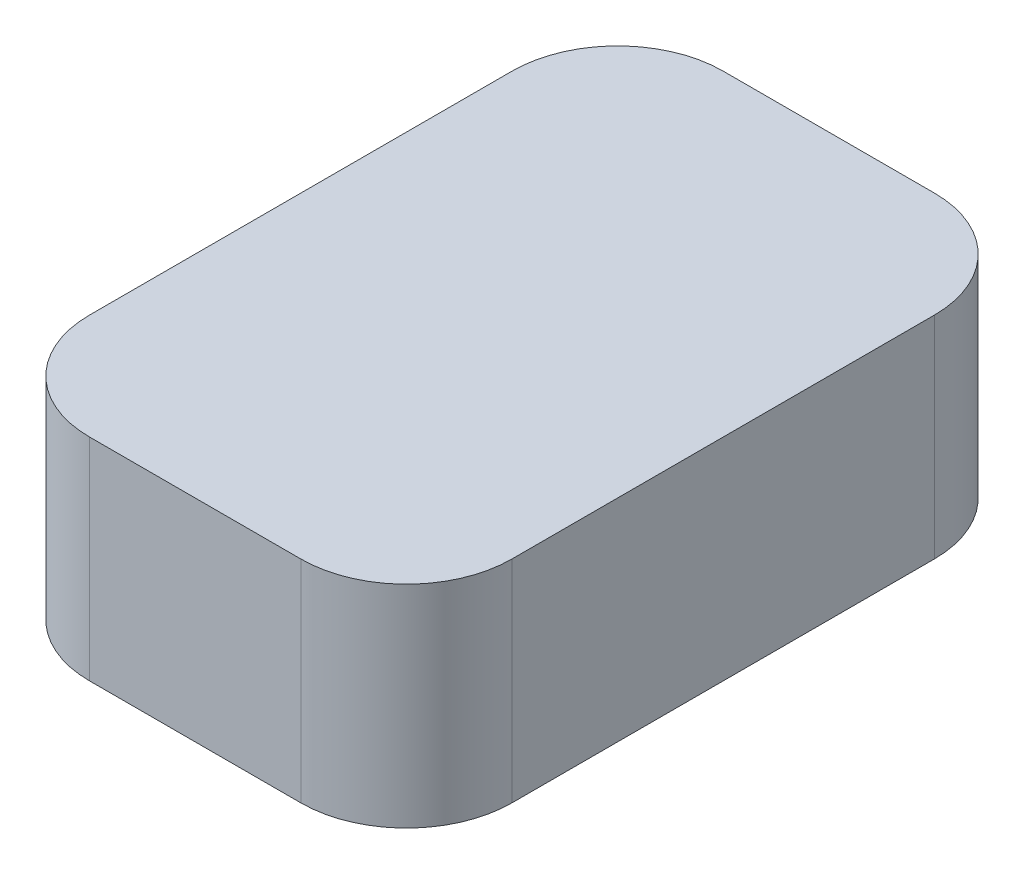
from build123d import *

# Parameters (mm, degrees)
SKETCH2_W           = 20
SKETCH2_H           = 30
BOSS_EXTRUDE1_DEPTH = 10
FILLET1_R           = 5


with BuildPart() as part:
    # Sketch2 → Boss-Extrude1 (new body)
    with BuildSketch(Plane(origin=(0, 0, 0), x_dir=(1, 0, 0), z_dir=(0, 1, 0))):
        Rectangle(SKETCH2_W, SKETCH2_H)
    extrude(amount=-BOSS_EXTRUDE1_DEPTH)

    # Fillet1
    fillet1_edges = [part.edges().sort_by_distance(p)[0] for p in [
        (10, -5, 15),
        (-10, -5, 15),
        (-10, -5, -15),
        (10, -5, -15),
    ]]
    fillet(fillet1_edges, radius=FILLET1_R)


solid = part.part
